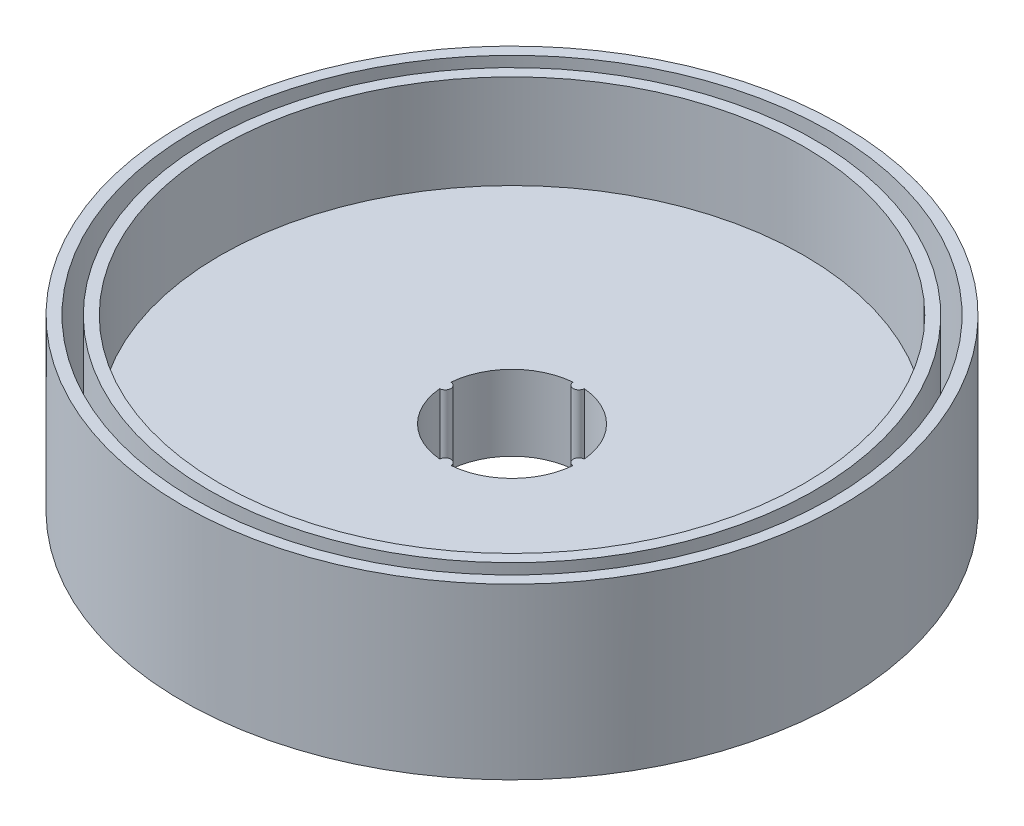
from build123d import *

# Parameters (mm, degrees)
SKETCH1_R           = 17.5
SKETCH1_R_2         = 15.5
BOSS_EXTRUDE1_DEPTH = 5
SKETCH3_R           = 17.5
BOSS_EXTRUDE2_DEPTH = 4
SKETCH2_R           = 16.9
SKETCH2_R_2         = 16.1
CUT_EXTRUDE1_DEPTH  = 8


with BuildPart() as part:
    # Sketch1 → Boss-Extrude1 (new body)
    with BuildSketch(Plane(origin=(0, 0, 0), x_dir=(1, 0, 0), z_dir=(0, 1, 0))):
        Circle(SKETCH1_R)
        Circle(SKETCH1_R_2, mode=Mode.SUBTRACT)
    extrude(amount=BOSS_EXTRUDE1_DEPTH)

    # Sketch3 → Boss-Extrude2 (add)
    with BuildSketch(Plane.XZ):
        Circle(SKETCH3_R)
        with BuildLine():
            ThreePointArc((-0.299732076, 3.537323944), (-2.510229073, 2.510229073), (-3.537323944, 0.299732076))
            ThreePointArc((-3.537323944, 0.299732076), (-3.25, 0), (-3.537323944, -0.299732076))
            ThreePointArc((-3.537323944, -0.299732076), (-2.510229073, -2.510229073), (-0.299732076, -3.537323944))
            ThreePointArc((-0.299732076, -3.537323944), (0, -3.25), (0.299732076, -3.537323944))
            ThreePointArc((0.299732076, -3.537323944), (2.510229073, -2.510229073), (3.537323944, -0.299732076))
            ThreePointArc((3.537323944, -0.299732076), (3.25, 0), (3.537323944, 0.299732076))
            ThreePointArc((3.537323944, 0.299732076), (2.510229073, 2.510229073), (0.299732076, 3.537323944))
            ThreePointArc((0.299732076, 3.537323944), (0, 3.25), (-0.299732076, 3.537323944))
        make_face(mode=Mode.SUBTRACT)
    extrude(amount=BOSS_EXTRUDE2_DEPTH)

    # Sketch2 → Cut-Extrude1 (cut)
    with BuildSketch(Plane(origin=(0, 5, 0), x_dir=(1, 0, 0), z_dir=(0, 1, 0))):
        Circle(SKETCH2_R)
        Circle(SKETCH2_R_2, mode=Mode.SUBTRACT)
    extrude(amount=-CUT_EXTRUDE1_DEPTH, mode=Mode.SUBTRACT)


solid = part.part
